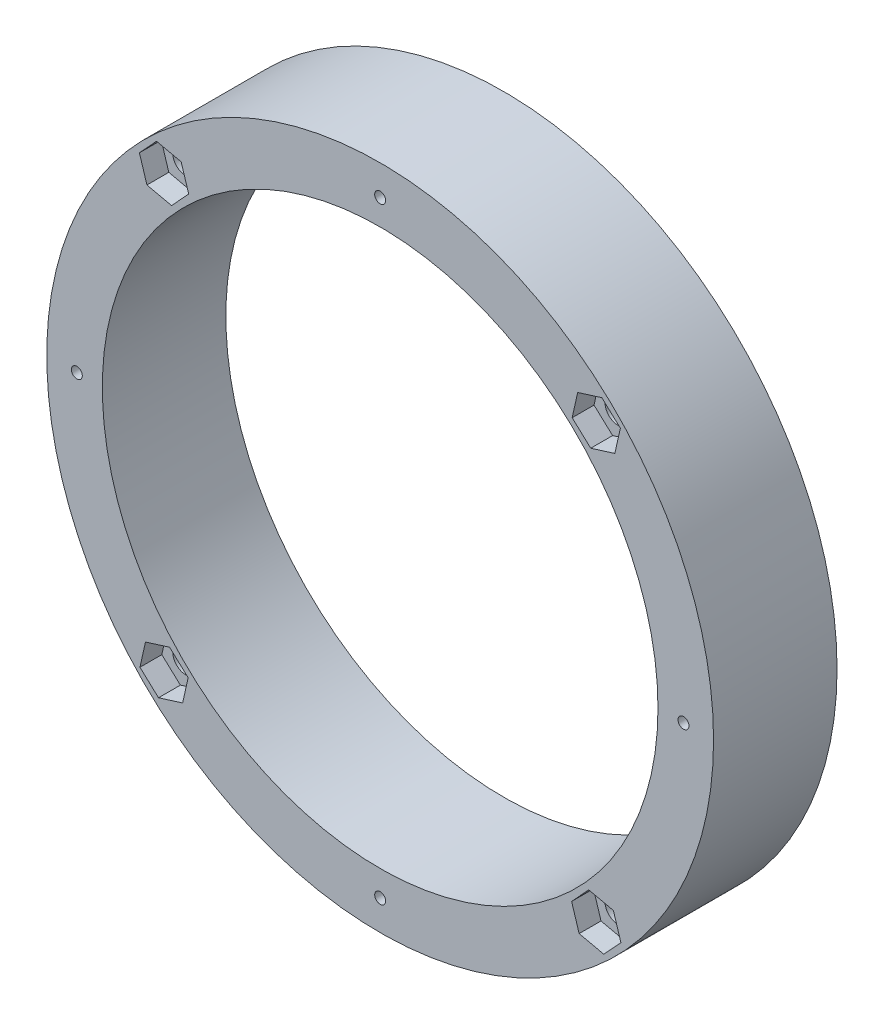
from build123d import *

# Parameters (mm, degrees)
SKETCH1_R           = 76.2
SKETCH1_R_2         = 63.5
SKETCH1_R_3         = 1.25
BOSS_EXTRUDE1_DEPTH = 28.225
SKETCH2_R           = 2.5
CUT_EXTRUDE1_DEPTH  = 6.725
SKETCH3_R           = 3
CUT_EXTRUDE2_DEPTH  = 29.225
CUT_EXTRUDE3_DEPTH  = 5


with BuildPart() as part:
    # Sketch1 → Boss-Extrude1 (new body)
    with BuildSketch(Plane.XY):
        Circle(SKETCH1_R)
        Circle(SKETCH1_R_2, mode=Mode.SUBTRACT)
        with Locations((0, 69.3225)):
            Circle(SKETCH1_R_3, mode=Mode.SUBTRACT)
        with Locations((69.3225, 0)):
            Circle(SKETCH1_R_3, mode=Mode.SUBTRACT)
        with Locations((0, -69.3225)):
            Circle(SKETCH1_R_3, mode=Mode.SUBTRACT)
        with Locations((-69.3225, 0)):
            Circle(SKETCH1_R_3, mode=Mode.SUBTRACT)
    extrude(amount=BOSS_EXTRUDE1_DEPTH)

    # Sketch2 → Cut-Extrude1 (cut)
    with BuildSketch(Plane(origin=(0, 0, 0), x_dir=(-1, 0, 0), z_dir=(0, 0, -1))):
        with Locations((0, 69.3225)):
            Circle(SKETCH2_R)
        with Locations((69.3225, 0)):
            Circle(SKETCH2_R)
        with Locations((0, -69.3225)):
            Circle(SKETCH2_R)
        with Locations((-69.3225, 0)):
            Circle(SKETCH2_R)
    extrude(amount=-CUT_EXTRUDE1_DEPTH, mode=Mode.SUBTRACT)

    # Sketch3 → Cut-Extrude2 (cut, through all)
    with BuildSketch(Plane.XY.offset(28.225)):
        with Locations((-49.391408666, 49.391408666)):
            Circle(SKETCH3_R)
        with Locations((49.391408666, 49.391408666)):
            Circle(SKETCH3_R)
        with Locations((49.391408666, -49.391408666)):
            Circle(SKETCH3_R)
        with Locations((-49.391408666, -49.391408666)):
            Circle(SKETCH3_R)
    extrude(amount=-CUT_EXTRUDE2_DEPTH, mode=Mode.SUBTRACT)

    # Sketch4 → Cut-Extrude3 (cut)
    with BuildSketch(Plane.XY.offset(28.225)):
        Polygon((48.127283598, 43.757997511), (53.638023302, 45.479938666), (54.90214837, 51.113349821), (50.655533734, 55.024819821), (45.14479403, 53.302878666), (43.880668962, 47.669467511), align=None)
        Polygon((-43.757997511, 48.127283598), (-45.479938666, 53.638023302), (-51.113349821, 54.90214837), (-55.024819821, 50.655533734), (-53.302878666, 45.14479403), (-47.669467511, 43.880668962), align=None)
        Polygon((43.757997511, -48.127283598), (45.479938666, -53.638023302), (51.113349821, -54.90214837), (55.024819821, -50.655533734), (53.302878666, -45.14479403), (47.669467511, -43.880668962), align=None)
        Polygon((-48.127283598, -43.757997511), (-53.638023302, -45.479938666), (-54.90214837, -51.113349821), (-50.655533734, -55.024819821), (-45.14479403, -53.302878666), (-43.880668962, -47.669467511), align=None)
    extrude(amount=-CUT_EXTRUDE3_DEPTH, mode=Mode.SUBTRACT)


solid = part.part
